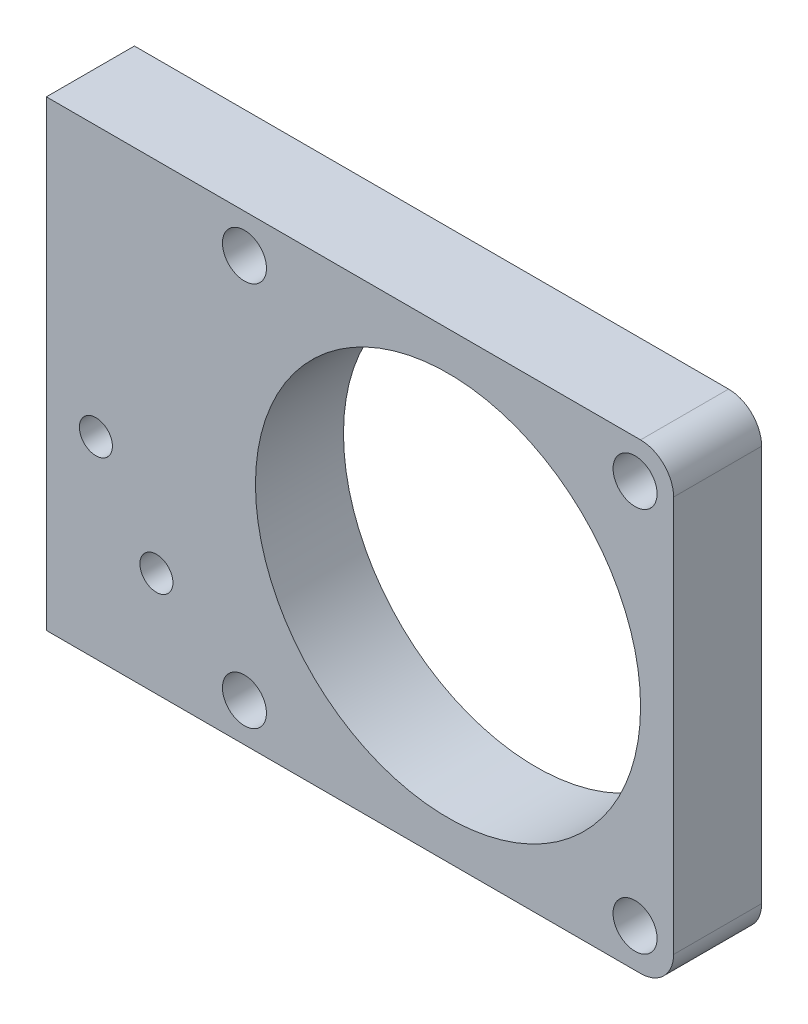
from build123d import *

# Parameters (mm, degrees)
SKETCH1_W           = 57
SKETCH1_H           = 42
BOSS_EXTRUDE1_DEPTH = 8
SKETCH2_R           = 17.5
SKETCH2_R_2         = 2
SKETCH2_R_3         = 1.5
CUT_EXTRUDE1_DEPTH  = 9
FILLET1_R           = 3
FILLET2_R           = 3
SKETCH3_R           = 2
CUT_EXTRUDE2_DEPTH  = 13


with BuildPart() as part:
    # Sketch1 → Boss-Extrude1 (new body)
    with BuildSketch(Plane.XY):
        Rectangle(SKETCH1_W, SKETCH1_H)
    extrude(amount=BOSS_EXTRUDE1_DEPTH)

    # Sketch2 → Cut-Extrude1 (cut, through all)
    with BuildSketch(Plane.XY.offset(8)):
        with Locations((8, 0)):
            Circle(SKETCH2_R)
        with Locations((25, 17.5)):
            Circle(SKETCH2_R_2)
        with Locations((-10.5, 17.5)):
            Circle(SKETCH2_R_2)
        with Locations((25, -17.5)):
            Circle(SKETCH2_R_2)
        with Locations((-10.5, -17.5)):
            Circle(SKETCH2_R_2)
        with Locations((-18.5, -11.5)):
            Circle(SKETCH2_R_3)
        with Locations((-24, -3.5)):
            Circle(SKETCH2_R_3)
    extrude(amount=-CUT_EXTRUDE1_DEPTH, mode=Mode.SUBTRACT)

    # Fillet1
    fillet1_edges = [part.edges().sort_by_distance(p)[0] for p in [
        (28.5, -21, 4),
    ]]
    fillet(fillet1_edges, radius=FILLET1_R)

    # Fillet2
    fillet2_edges = [part.edges().sort_by_distance(p)[0] for p in [
        (28.5, 21, 4),
    ]]
    fillet(fillet2_edges, radius=FILLET2_R)

    # Sketch3 → Cut-Extrude2 (cut)
    with BuildSketch(Plane.ZY.offset(28.5)):
        with Locations((4, 16)):
            Circle(SKETCH3_R)
        with Locations((4, -16)):
            Circle(SKETCH3_R)
    extrude(amount=-CUT_EXTRUDE2_DEPTH, mode=Mode.SUBTRACT)


solid = part.part
